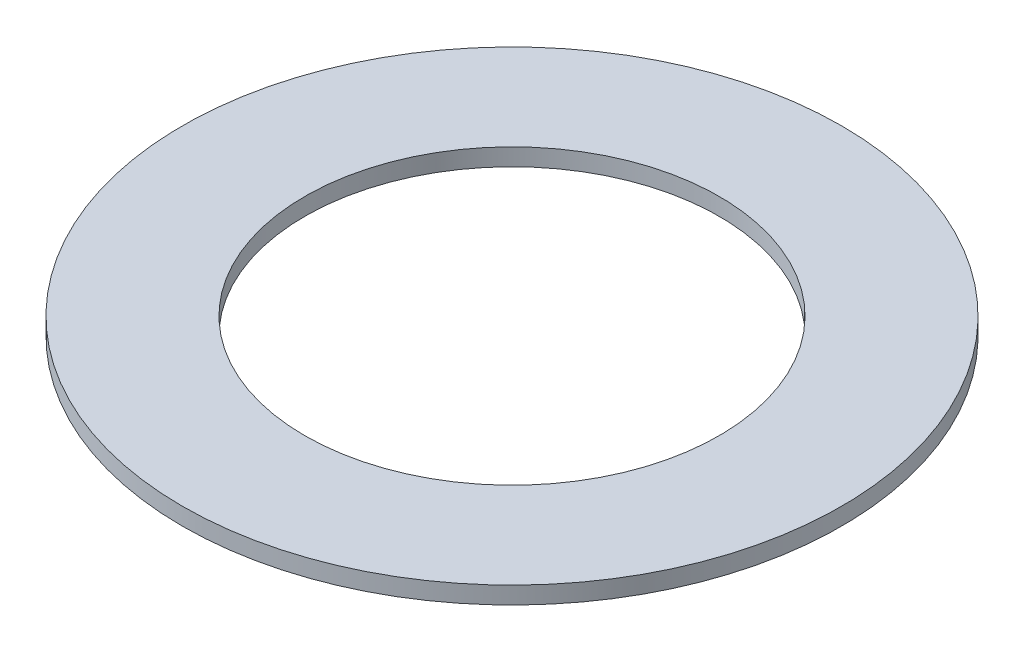
from build123d import *

# Parameters (mm, degrees)
ESQUISSE1_R        = 5.725
ESQUISSE1_R_2      = 3.6
BOSS_EXTRU_1_DEPTH = 0.3


with BuildPart() as part:
    # Esquisse1 → Boss.-Extru.1 (new body)
    with BuildSketch(Plane(origin=(0, 0, 0), x_dir=(1, 0, 0), z_dir=(0, 1, 0))):
        Circle(ESQUISSE1_R)
        Circle(ESQUISSE1_R_2, mode=Mode.SUBTRACT)
    extrude(amount=BOSS_EXTRU_1_DEPTH)


solid = part.part
